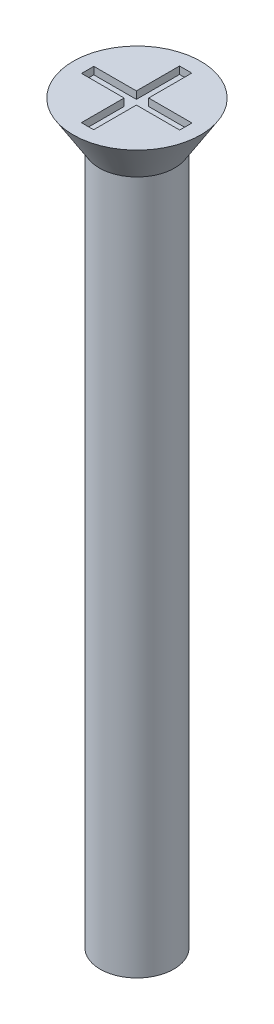
from build123d import *

# Parameters (mm, degrees)
SKETCH1_R           = 1.5
BOSS_EXTRUDE1_DEPTH = 30
SKETCH2_R           = 2.6
BOSS_EXTRUDE2_DEPTH = 1.7
BOSS_EXTRUDE2_TAPER = 32
SKETCH3_W           = 0.5
SKETCH3_H           = 1.758378485
SKETCH3_H_2         = 1.741621515
SKETCH3_W_2         = 1.734727157
SKETCH3_H_3         = 0.5
SKETCH3_W_3         = 1.765272843
CUT_EXTRUDE1_DEPTH  = 0.3


with BuildPart() as part:
    # Sketch1 → Boss-Extrude1 (new body)
    with BuildSketch(Plane(origin=(0, 0, 0), x_dir=(1, 0, 0), z_dir=(0, 1, 0))):
        Circle(SKETCH1_R)
    extrude(amount=BOSS_EXTRUDE1_DEPTH)

    # Sketch2 → Boss-Extrude2 (add)
    with BuildSketch(Plane(origin=(0, 30, 0), x_dir=(1, 0, 0), z_dir=(0, 1, 0))):
        Circle(SKETCH2_R)
    extrude(amount=-BOSS_EXTRUDE2_DEPTH, taper=BOSS_EXTRUDE2_TAPER)

    # Sketch3 → Cut-Extrude1 (cut)
    with BuildSketch(Plane(origin=(0, 30, 0), x_dir=(1, 0, 0), z_dir=(0, 1, 0))):
        with Locations((-0.015272843, 1.120810757)):
            Rectangle(SKETCH3_W, SKETCH3_H)
        with Locations((-0.015272843, -1.129189243)):
            Rectangle(SKETCH3_W, SKETCH3_H_2)
        with Locations((-1.132636421, -0.008378485)):
            Rectangle(SKETCH3_W_2, SKETCH3_H_3)
        with Locations((1.117363579, -0.008378485)):
            Rectangle(SKETCH3_W_3, SKETCH3_H_3)
        with Locations((-0.015272843, -0.008378485)):
            Rectangle(SKETCH3_W, SKETCH3_H_3)
    extrude(amount=-CUT_EXTRUDE1_DEPTH, mode=Mode.SUBTRACT)


solid = part.part
